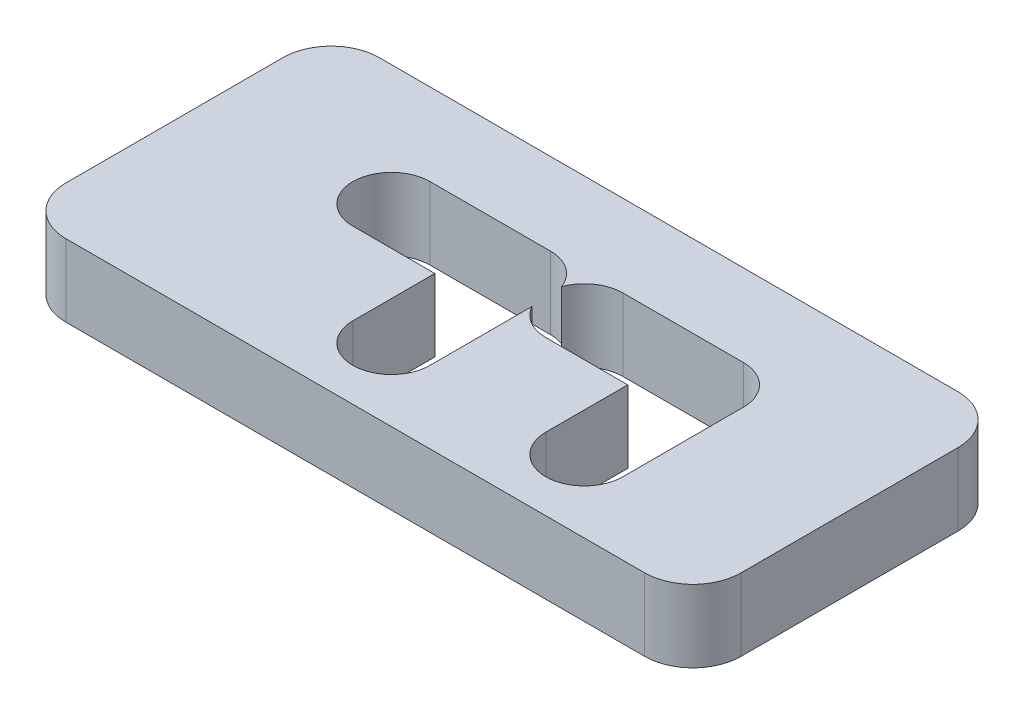
from build123d import *

# Parameters (mm, degrees)
SKETCH1_W           = 28
SKETCH1_H           = 30
BOSS_EXTRUDE1_DEPTH = 3
SKETCH2_R           = 1.6
CUT_EXTRUDE1_DEPTH  = 4
SKETCH3_W           = 28
SKETCH3_H           = 17
CUT_EXTRUDE2_DEPTH  = 4
FILLET1_R           = 2


with BuildPart() as part:
    # Sketch1 → Boss-Extrude1 (new body)
    with BuildSketch(Plane(origin=(0, 0, 0), x_dir=(1, 0, 0), z_dir=(0, 1, 0))):
        Rectangle(SKETCH1_W, SKETCH1_H)
        with BuildLine():
            ThreePointArc((1.5, 8.4), (0.687397597, 8.621712173), (0.1, 9.225403331))
            Line((0.1, 9.225403331), (0.1, 5))
            ThreePointArc((0.1, 5), (-1.5, 3.4), (-3.1, 5))
            Line((-3.1, 5), (-3.1, 8.4))
            Line((-3.1, 8.4), (-6.5, 8.4))
            ThreePointArc((-6.5, 8.4), (-8.1, 10), (-6.5, 11.6))
            Line((-6.5, 11.6), (-1.5, 11.6))
            ThreePointArc((-1.5, 11.6), (-0.586447127, 11.313552873), (0, 10.556776436))
            ThreePointArc((0, 10.556776436), (0.586447127, 11.313552873), (1.5, 11.6))
            Line((1.5, 11.6), (6.5, 11.6))
            ThreePointArc((6.5, 11.6), (7.63137085, 11.13137085), (8.1, 10))
            Line((8.1, 10), (8.1, 5))
            ThreePointArc((8.1, 5), (6.5, 3.4), (4.9, 5))
            Line((4.9, 5), (4.9, 8.4))
            Line((4.9, 8.4), (1.5, 8.4))
        make_face(mode=Mode.SUBTRACT)
    extrude(amount=BOSS_EXTRUDE1_DEPTH)

    # Sketch2 → Cut-Extrude1 (cut, through all)
    with BuildSketch(Plane(origin=(0, 3, 0), x_dir=(1, 0, 0), z_dir=(0, 1, 0))):
        with Locations((-5.25, -10)):
            Circle(SKETCH2_R)
        with Locations((5.25, -10)):
            Circle(SKETCH2_R)
        Polygon((14, 0), (8.5, -15), (14, -15), align=None)
        Polygon((-8.5, -15), (-14, -15), (-14, 0), align=None)
    extrude(amount=-CUT_EXTRUDE1_DEPTH, mode=Mode.SUBTRACT)

    # Sketch3 → Cut-Extrude2 (cut, through all)
    with BuildSketch(Plane(origin=(0, 3, 0), x_dir=(1, 0, 0), z_dir=(0, 1, 0))):
        with Locations((0, -6.5)):
            Rectangle(SKETCH3_W, SKETCH3_H)
    extrude(amount=-CUT_EXTRUDE2_DEPTH, mode=Mode.SUBTRACT)

    # Fillet1
    fillet1_edges = [part.edges().sort_by_distance(p)[0] for p in [
        (-14, 1.5, -15),
        (14, 1.5, -15),
        (14, 1.5, -2),
        (-14, 1.5, -2),
    ]]
    fillet(fillet1_edges, radius=FILLET1_R)


solid = part.part
